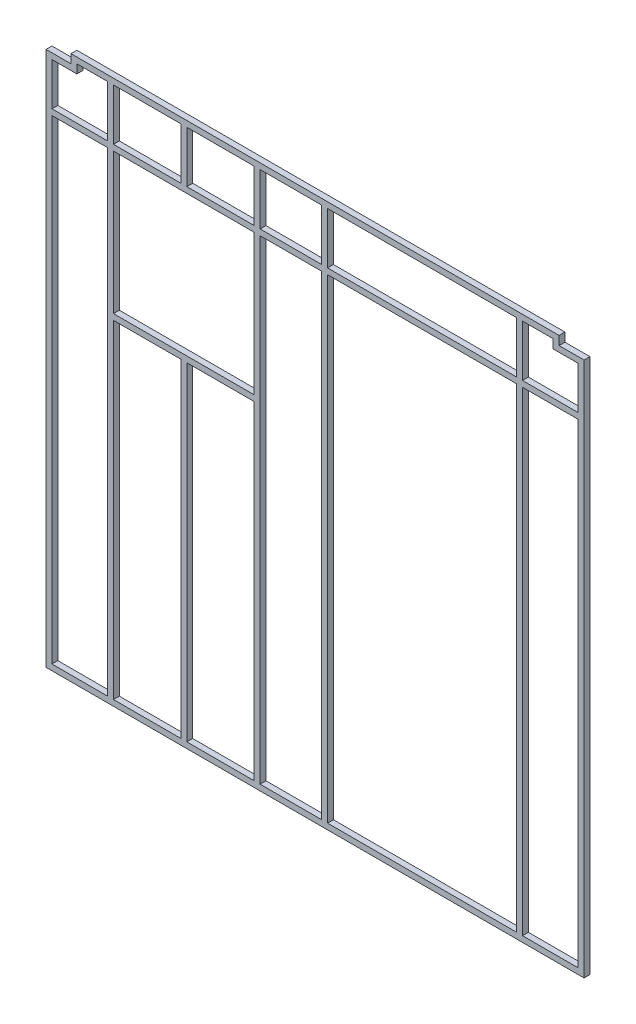
from build123d import *

# Parameters (mm, degrees)
SKETCH2_W             = 25.4
SKETCH2_H             = 25.4
SKETCH2_W_2           = 19.05
SKETCH2_H_2           = 19.05
SKETCH3_W             = 25.4
SKETCH3_H             = 25.4
SKETCH3_W_2           = 19.05
SKETCH3_H_2           = 19.05
BOSS_EXTRUDE1_DEPTH   = 2305.558
BOSS_EXTRUDE1_2_DEPTH = 2305.558
BOSS_EXTRUDE1_3_DEPTH = 2305.558
BOSS_EXTRUDE1_4_DEPTH = 2305.558
BOSS_EXTRUDE1_5_DEPTH = 2305.558
BOSS_EXTRUDE2_START   = -108.204
SKETCH5_W             = 25.4
SKETCH5_H             = 25.4
SKETCH5_W_2           = 19.05
SKETCH5_H_2           = 19.05
BOSS_EXTRUDE2_DEPTH   = 2279.65
CUT_EXTRUDE1_REACH    = 27.4
SKETCH6_W             = 609.6
SKETCH6_H             = 635
SKETCH7_W             = 25.4
SKETCH7_H             = 25.4
BOSS_EXTRUDE3_DEPTH   = 609.6


with BuildPart() as part:
    # Sweep1: sweep along a path in Sketch1
    with BuildLine(Plane.XY) as sweep1_path:
        Line((-1057.021, 2356.358), (1057.021, 2356.358))
        Line((1057.021, 2356.358), (1057.021, 2318.258))
        Line((1057.021, 2318.258), (1165.225, 2318.258))
        Line((1165.225, 2318.258), (1165.225, 0))
        Line((1165.225, 0), (-1165.225, 0))
        Line((-1165.225, 0), (-1165.225, 2318.258))
        Line((-1165.225, 2318.258), (-1057.021, 2318.258))
        Line((-1057.021, 2318.258), (-1057.021, 2356.358))
    # Sketch2 → Sweep1 (sweep)
    with BuildSketch(Plane(origin=(0, 0, 0), x_dir=(0, 0, -1), z_dir=(1, 0, 0))):
        with Locations((0, 12.7)):
            Rectangle(SKETCH2_W, SKETCH2_H)
        with Locations((0, 12.7)):
            Rectangle(SKETCH2_W_2, SKETCH2_H_2, mode=Mode.SUBTRACT)
    sweep(path=sweep1_path.line, transition=Transition.RIGHT)



with BuildPart() as body_2:
    # Sketch3 → Boss-Extrude1 (new body)
    with BuildSketch(Plane(origin=(0, 25.4, 0), x_dir=(1, 0, 0), z_dir=(0, 1, 0))):
        with Locations((885.825, 0)):
            Rectangle(SKETCH3_W, SKETCH3_H)
        with Locations((885.825, 0)):
            Rectangle(SKETCH3_W_2, SKETCH3_H_2, mode=Mode.SUBTRACT)
    extrude(amount=BOSS_EXTRUDE1_DEPTH)


with BuildPart() as body_3:
    # Sketch3 → Boss-Extrude1 2 (new body)
    with BuildSketch(Plane(origin=(0, 25.4, 0), x_dir=(1, 0, 0), z_dir=(0, 1, 0))):
        with Locations((-568.325, 0)):
            Rectangle(SKETCH3_W, SKETCH3_H)
        with Locations((-568.325, 0)):
            Rectangle(SKETCH3_W_2, SKETCH3_H_2, mode=Mode.SUBTRACT)
    extrude(amount=BOSS_EXTRUDE1_2_DEPTH)


with BuildPart() as body_4:
    # Sketch3 → Boss-Extrude1 3 (new body)
    with BuildSketch(Plane(origin=(0, 25.4, 0), x_dir=(1, 0, 0), z_dir=(0, 1, 0))):
        with Locations((-885.825, 0)):
            Rectangle(SKETCH3_W, SKETCH3_H)
        with Locations((-885.825, 0)):
            Rectangle(SKETCH3_W_2, SKETCH3_H_2, mode=Mode.SUBTRACT)
    extrude(amount=BOSS_EXTRUDE1_3_DEPTH)


with BuildPart() as body_5:
    # Sketch3 → Boss-Extrude1 4 (new body)
    with BuildSketch(Plane(origin=(0, 25.4, 0), x_dir=(1, 0, 0), z_dir=(0, 1, 0))):
        with Locations((41.275, 0)):
            Rectangle(SKETCH3_W, SKETCH3_H)
        with Locations((41.275, 0)):
            Rectangle(SKETCH3_W_2, SKETCH3_H_2, mode=Mode.SUBTRACT)
    extrude(amount=BOSS_EXTRUDE1_4_DEPTH)


with BuildPart() as body_6:
    # Sketch3 → Boss-Extrude1 5 (new body)
    with BuildSketch(Plane(origin=(0, 25.4, 0), x_dir=(1, 0, 0), z_dir=(0, 1, 0))):
        with Locations((-250.825, 0)):
            Rectangle(SKETCH3_W, SKETCH3_H)
        with Locations((-250.825, 0)):
            Rectangle(SKETCH3_W_2, SKETCH3_H_2, mode=Mode.SUBTRACT)
    extrude(amount=BOSS_EXTRUDE1_5_DEPTH)


with BuildPart() as part_1:
    add(part.part)

    add(body_2.part)  # Boss-Extrude2 merges body 2

    add(body_3.part)  # Boss-Extrude2 merges body 3

    add(body_4.part)  # Boss-Extrude2 merges body 4

    add(body_5.part)  # Boss-Extrude2 merges body 5

    add(body_6.part)  # Boss-Extrude2 merges body 6
    # Sketch5 → Boss-Extrude2 (add)
    with BuildSketch(Plane.ZY.offset(-1031.621).offset(BOSS_EXTRUDE2_START)):
        with Locations((0, 2095.5)):
            Rectangle(SKETCH5_W, SKETCH5_H)
        with Locations((0, 2095.5)):
            Rectangle(SKETCH5_W_2, SKETCH5_H_2, mode=Mode.SUBTRACT)
    extrude(amount=BOSS_EXTRUDE2_DEPTH)

    # Sketch6 → Cut-Extrude1 (cut, up to next)
    with BuildSketch(Plane.XY.offset(12.7), mode=Mode.PRIVATE) as cut_extrude1_sk1:
        with Locations((-568.325, 1765.3)):
            Rectangle(SKETCH6_W, SKETCH6_H)
    cut_extrude1_tool1 = extrude(cut_extrude1_sk1.sketch, amount=-CUT_EXTRUDE1_REACH, mode=Mode.PRIVATE) & part_1.part
    add(cut_extrude1_tool1.solids().sort_by_distance((-568.325, 1765.3, 12.7))[0], mode=Mode.SUBTRACT)

    # Sketch7 → Boss-Extrude3 (add)
    with BuildSketch(Plane(origin=(-873.125, 0, 0), x_dir=(0, 0, -1), z_dir=(1, 0, 0))):
        with Locations((0, 1460.5)):
            Rectangle(SKETCH7_W, SKETCH7_H)
    extrude(amount=BOSS_EXTRUDE3_DEPTH)


solid = part_1.part
